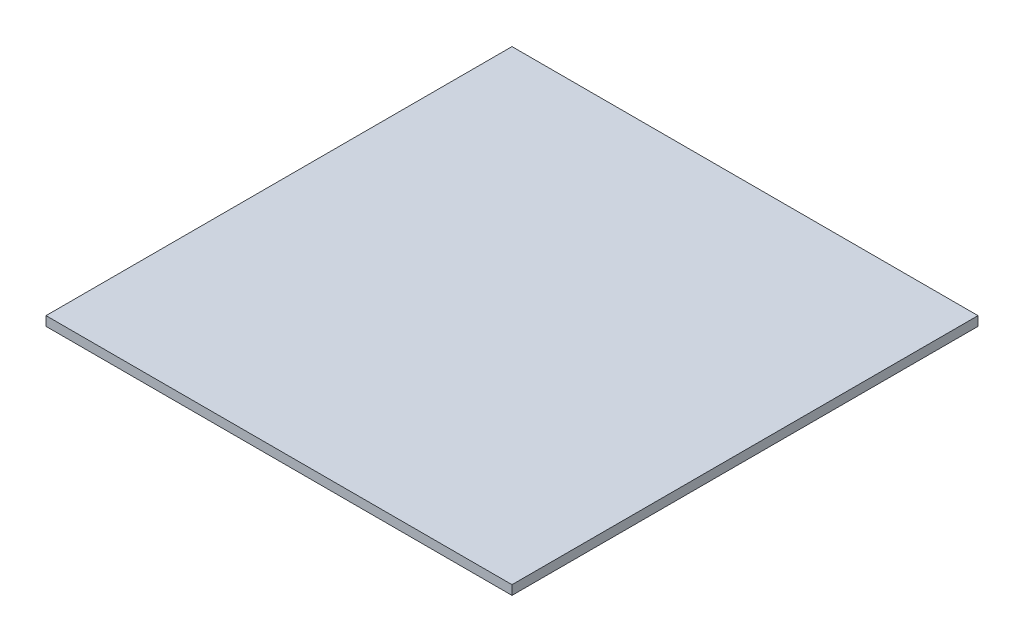
from build123d import *

# Parameters (mm, degrees)
SKIZZE2_W                       = 1000
SKIZZE2_H                       = 1000
AUFSATZ_LINEAR_AUSTRAGEN1_DEPTH = 20


with BuildPart() as part:
    # Skizze2 → Aufsatz-Linear austragen1 (new body)
    with BuildSketch(Plane(origin=(0, 0, 0), x_dir=(1, 0, 0), z_dir=(0, 1, 0))):
        Rectangle(SKIZZE2_W, SKIZZE2_H)
    extrude(amount=AUFSATZ_LINEAR_AUSTRAGEN1_DEPTH)


solid = part.part
